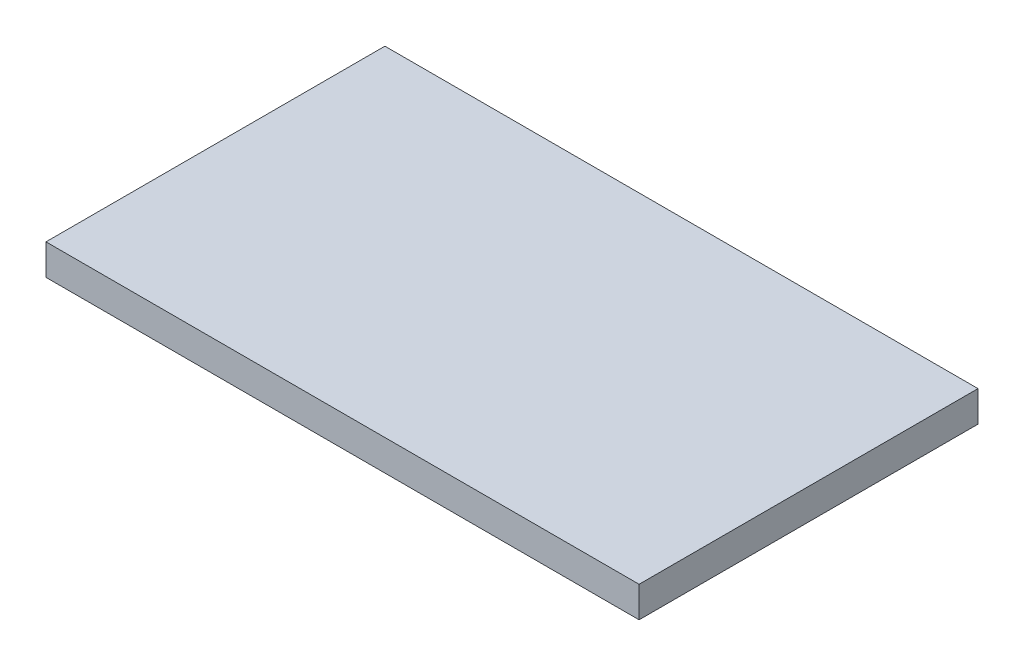
from build123d import *

# Parameters (mm, degrees)
SKETCH1_W           = 38.5
SKETCH1_H           = 22
BOSS_EXTRUDE1_DEPTH = 2


with BuildPart() as part:
    # Sketch1 → Boss-Extrude1 (new body)
    with BuildSketch(Plane(origin=(0, 0, 0), x_dir=(1, 0, 0), z_dir=(0, 1, 0))):
        Rectangle(SKETCH1_W, SKETCH1_H)
    extrude(amount=BOSS_EXTRUDE1_DEPTH)


solid = part.part
